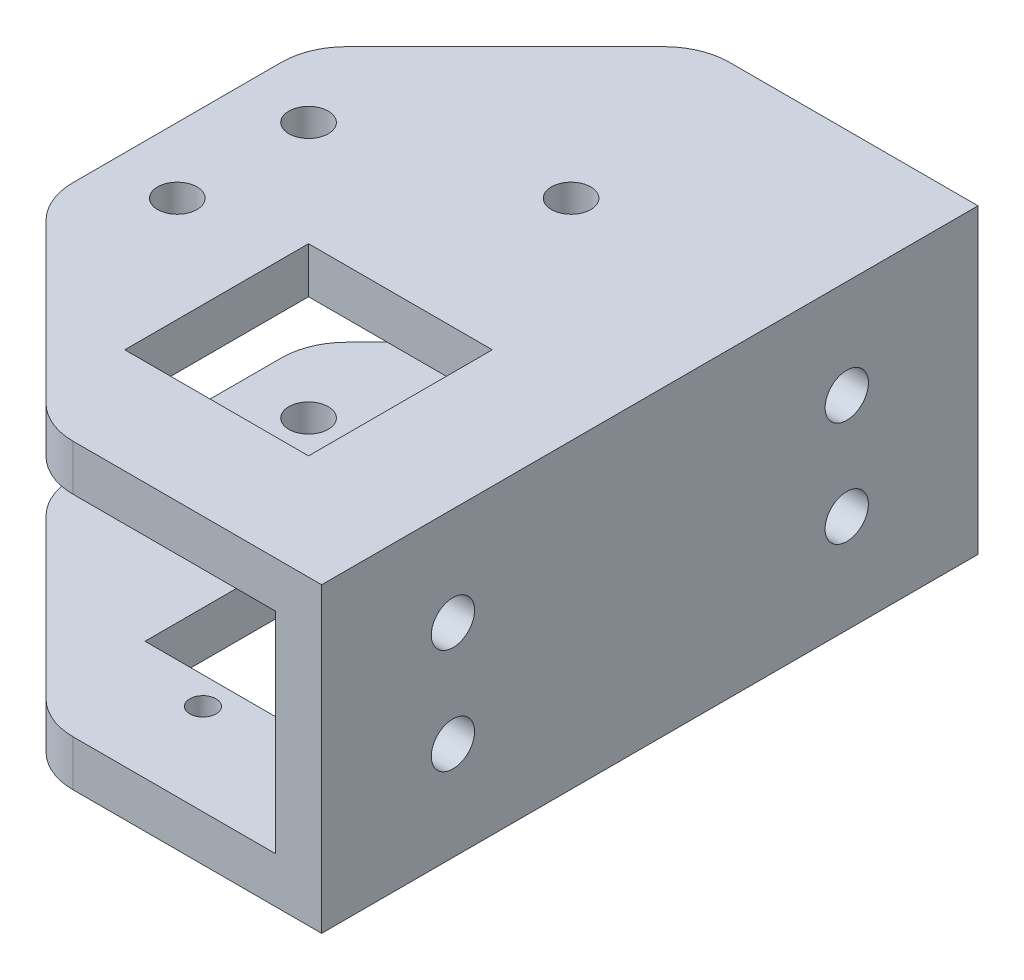
from build123d import *

# Parameters (mm, degrees)
EXTRUDE_1_DEPTH     = 50
CUT_EXTRUDE_START   = -19.5
SKETCH_2_R          = 1.5
CUT_EXTRUDE_1_DEPTH = 70
SKETCH_3_OUTSIDE_W  = 61.218
SKETCH_3_OUTSIDE_H  = 66.218
CUT_EXTRUDE_2_DEPTH = 70
SKETCH_2_3_R        = 1.5
CUT_EXTRUDE_4_DEPTH = 10
SKETCH_5_R          = 1
CUT_EXTRUDE_5_DEPTH = 10
FILLET_1_R          = 5
SKETCH_6_W          = 13
SKETCH_6_H          = 23.5
CUT_EXTRUDE_6_DEPTH = 10
SKETCH_7_R          = 1.65
CUT_EXTRUDE_7_DEPTH = 10
SKETCH_8_W          = 14
SKETCH_8_H          = 14
CUT_EXTRUDE_8_DEPTH = 10


with BuildPart() as part:
    # 草图1 → 凸台-拉伸1 (new body)
    with BuildSketch(Plane.XY):
        Polygon((-45, 11.5), (0, 11.5), (0, -11.5), (-45, -11.5), (-45, -8), (-3.5, -8), (-3.5, 8), (-45, 8), align=None)
    extrude(amount=EXTRUDE_1_DEPTH)

    # 草图2 → 切除-拉伸1 (cut)
    with BuildSketch(Plane.XZ.offset(11.5).offset(CUT_EXTRUDE_START)):
        with Locations((-16, 35)):
            Circle(SKETCH_2_R)
        with Locations((-16, 15)):
            Circle(SKETCH_2_R)
        with Locations((-31, 30)):
            Circle(SKETCH_2_R)
        with Locations((-31, 20)):
            Circle(SKETCH_2_R)
    extrude(amount=-CUT_EXTRUDE_1_DEPTH, mode=Mode.SUBTRACT)

    # 草图3 outside → 切除-拉伸2 (cut)
    with BuildSketch(Plane.XZ.offset(11.5)):
        with Locations((-22.5, 25)):
            Rectangle(SKETCH_3_OUTSIDE_W, SKETCH_3_OUTSIDE_H)
        Polygon((-21, 0), (-36, 15), (-36, 35), (-21, 50), (0, 50), (0, 0), align=None, mode=Mode.SUBTRACT)
    extrude(amount=-CUT_EXTRUDE_2_DEPTH, mode=Mode.SUBTRACT)

    # 草图2<3> → 切除-拉伸4 (cut)
    with BuildSketch(Plane.XZ.offset(11.5)):
        with Locations((-31, 30)):
            Circle(SKETCH_2_3_R)
        with Locations((-31, 20)):
            Circle(SKETCH_2_3_R)
    extrude(amount=-CUT_EXTRUDE_4_DEPTH, mode=Mode.SUBTRACT)

    # 草图5 → 切除-拉伸5 (cut)
    with BuildSketch(Plane.XZ.offset(11.5)):
        with Locations((-16, 43.045)):
            Circle(SKETCH_5_R)
        with Locations((-16, 15.375)):
            Circle(SKETCH_5_R)
    extrude(amount=-CUT_EXTRUDE_5_DEPTH, mode=Mode.SUBTRACT)

    # 圆角1
    fillet_1_edges = [part.edges().sort_by_distance(p)[0] for p in [
        (-21, -9.75, 0),
        (-21, 9.75, 0),
        (-21, -9.75, 50),
        (-21, 9.75, 50),
        (-36, 9.75, 35),
        (-36, -9.75, 35),
        (-36, 9.75, 15),
        (-36, -9.75, 15),
    ]]
    fillet(fillet_1_edges, radius=FILLET_1_R)

    # 草图6 → 切除-拉伸6 (cut)
    with BuildSketch(Plane.XZ.offset(11.5)):
        with Locations((-16, 29.21)):
            Rectangle(SKETCH_6_W, SKETCH_6_H)
    extrude(amount=-CUT_EXTRUDE_6_DEPTH, mode=Mode.SUBTRACT)

    # 草图7 → 切除-拉伸7 (cut)
    with BuildSketch(Plane(origin=(0, 0, 0), x_dir=(0, 0, -1), z_dir=(1, 0, 0))):
        with Locations((-10, 4)):
            Circle(SKETCH_7_R)
        with Locations((-40, 4)):
            Circle(SKETCH_7_R)
        with Locations((-10, -4)):
            Circle(SKETCH_7_R)
        with Locations((-40, -4)):
            Circle(SKETCH_7_R)
    extrude(amount=-CUT_EXTRUDE_7_DEPTH, mode=Mode.SUBTRACT)

    # 草图8 → 切除-拉伸8 (cut)
    with BuildSketch(Plane(origin=(0, 11.5, 0), x_dir=(1, 0, 0), z_dir=(0, 1, 0))):
        with Locations((-16, -35)):
            Rectangle(SKETCH_8_W, SKETCH_8_H)
    extrude(amount=-CUT_EXTRUDE_8_DEPTH, mode=Mode.SUBTRACT)


solid = part.part
